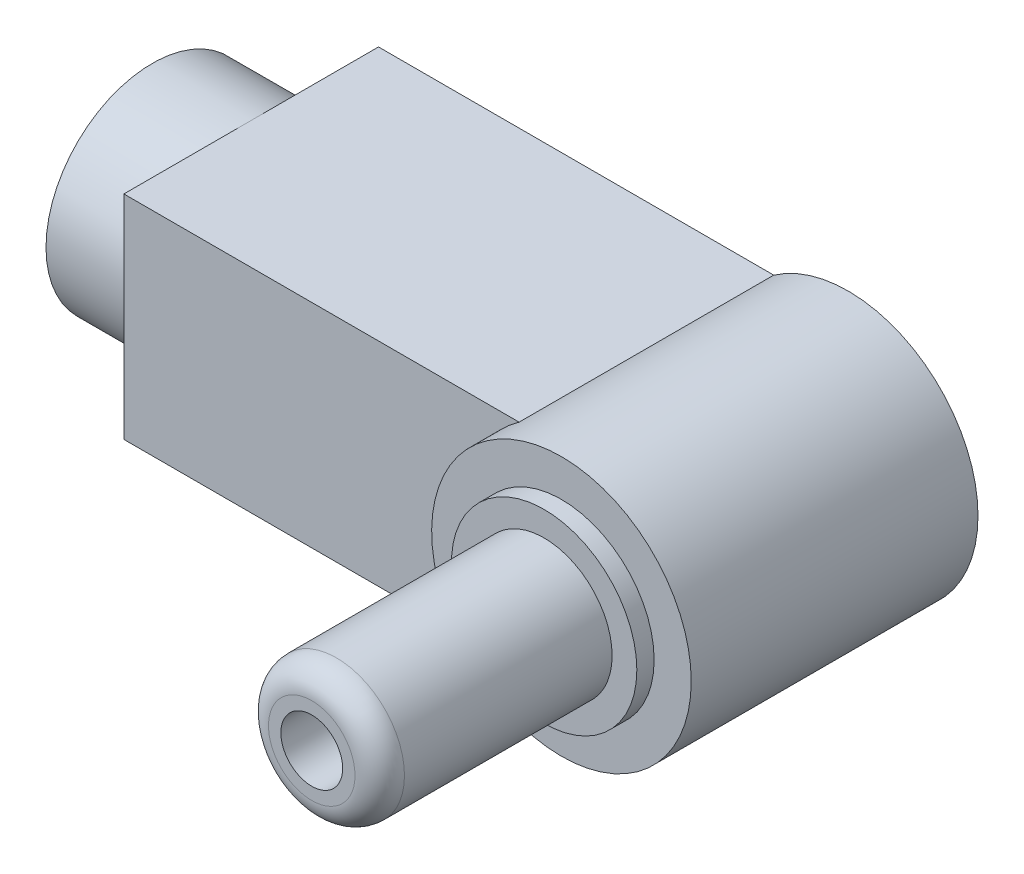
from build123d import *

# Parameters (mm, degrees)
BOSS_EXTRUDE1_DEPTH = 10.3
SKETCH2_R           = 5.25
BOSS_EXTRUDE2_DEPTH = 1.3
SKETCH3_R           = 3.75
BOSS_EXTRUDE3_DEPTH = 0.7
SKETCH4_R           = 2.75
SKETCH4_R_2         = 1.25
BOSS_EXTRUDE4_DEPTH = 9.4
FILLET1_R           = 1
SKETCH5_R           = 4.3
SKETCH5_R_2         = 2.75
BOSS_EXTRUDE5_DEPTH = 4


with BuildPart() as part:
    # Sketch1 → Boss-Extrude1 (new body)
    with BuildSketch(Plane.XY):
        with BuildLine():
            Line((-3.012059096, 4.3), (-19, 4.3))
            Line((-19, 4.3), (-19, -4.3))
            Line((-19, -4.3), (-3.012059096, -4.3))
            ThreePointArc((-3.012059096, -4.3), (5.25, 0), (-3.012059096, 4.3))
        make_face()
    extrude(amount=BOSS_EXTRUDE1_DEPTH)

    # Sketch2 → Boss-Extrude2 (add)
    with BuildSketch(Plane.XY.offset(10.3)):
        Circle(SKETCH2_R)
    extrude(amount=BOSS_EXTRUDE2_DEPTH)

    # Sketch3 → Boss-Extrude3 (add)
    with BuildSketch(Plane.XY.offset(11.6)):
        Circle(SKETCH3_R)
    extrude(amount=BOSS_EXTRUDE3_DEPTH)

    # Sketch4 → Boss-Extrude4 (add)
    with BuildSketch(Plane.XY.offset(12.3)):
        Circle(SKETCH4_R)
        Circle(SKETCH4_R_2, mode=Mode.SUBTRACT)
    extrude(amount=BOSS_EXTRUDE4_DEPTH)

    # Fillet1
    fillet1_edges = [part.edges().sort_by_distance(p)[0] for p in [
        (-2.75, 0, 21.7),
    ]]
    fillet(fillet1_edges, radius=FILLET1_R)

    # Sketch5 → Boss-Extrude5 (add)
    with BuildSketch(Plane.ZY.offset(19)):
        with Locations((5.15, 0)):
            Circle(SKETCH5_R)
        with Locations((5.15, 0)):
            Circle(SKETCH5_R_2, mode=Mode.SUBTRACT)
    extrude(amount=BOSS_EXTRUDE5_DEPTH)


solid = part.part
